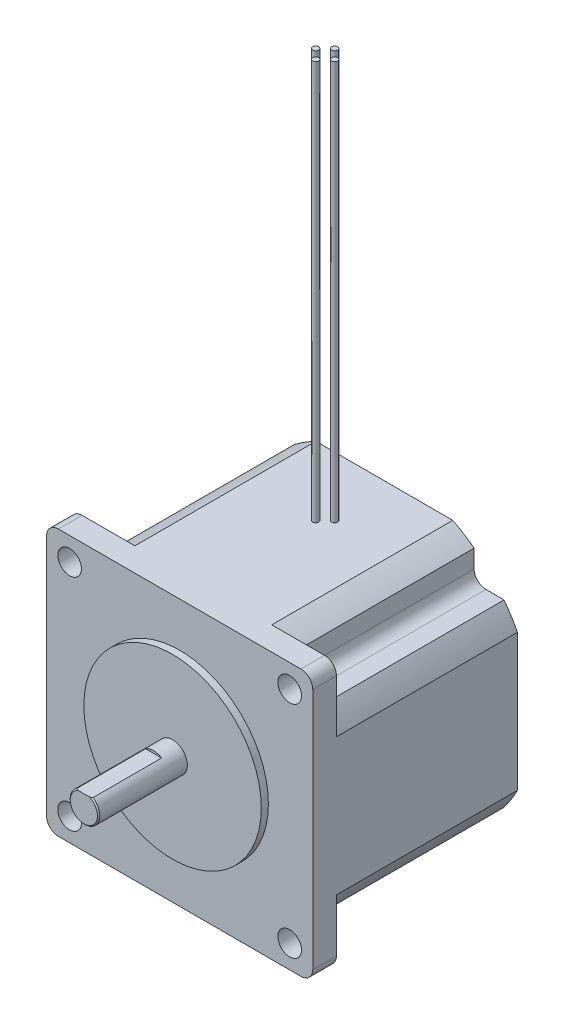
from build123d import *

# Parameters (mm, degrees)
ESQUISSE1_W             = 57.15
ESQUISSE1_H             = 57.15
BOSS_EXTRU_1_DEPTH      = 43.942
ENL_V_MAT_EXTRU_1_DEPTH = 38.862
ENL_V_MAT_EXTRU_2_DEPTH = 38.862
ENL_V_MAT_EXTRU_3_DEPTH = 38.862
ENL_V_MAT_EXTRU_4_DEPTH = 38.862
ENL_V_MAT_EXTRU_5_DEPTH = 38.862
ENL_V_MAT_EXTRU_6_DEPTH = 38.862
ENL_V_MAT_EXTRU_7_DEPTH = 38.862
ENL_V_MAT_EXTRU_8_DEPTH = 38.862
ESQUISSE10_R            = 19.05
BOSS_EXTRU_2_DEPTH      = 1.524
ESQUISSE11_R            = 3.175
BOSS_EXTRU_3_DEPTH      = 19.05
ENL_V_MAT_EXTRU_9_DEPTH = 14.986
ESQUISSE13_W            = 0.635
ESQUISSE13_H            = 85.725
ESQUISSE14_W            = 0.635
ESQUISSE14_H            = 85.725
ESQUISSE15_W            = 0.635
ESQUISSE15_H            = 85.725
ESQUISSE16_W            = 0.635
ESQUISSE16_H            = 85.725
PER_AGE1_D              = 5.08
PER_AGE1_DEPTH          = 25.654
CHANFREIN1_SIZE         = 0.254
CONG_1_R                = 2.54


with BuildPart() as part:
    # Esquisse1 → Boss.-Extru.1 (new body)
    with BuildSketch(Plane.XY.offset(43.942)):
        Rectangle(ESQUISSE1_W, ESQUISSE1_H)
    extrude(amount=-BOSS_EXTRU_1_DEPTH)

    # Esquisse2 → Enlèv. mat.-Extru.1 (cut)
    with BuildSketch(Plane(origin=(0, 0, 0), x_dir=(-1, 0, 0), z_dir=(0, 0, -1))):
        with BuildLine():
            Line((-28.575, -28.575), (-14.692533342, -28.575))
            ThreePointArc((-14.692533342, -28.575), (-22.720047986, -22.720047986), (-28.575, -14.692533342))
            Line((-28.575, -14.692533342), (-28.575, -28.575))
        make_face()
    extrude(amount=-ENL_V_MAT_EXTRU_1_DEPTH, mode=Mode.SUBTRACT)

    # Esquisse3 → Enlèv. mat.-Extru.2 (cut)
    with BuildSketch(Plane(origin=(0, 0, 0), x_dir=(-1, 0, 0), z_dir=(0, 0, -1))):
        with BuildLine():
            Line((-19.2786, -25.7048), (-19.2786, -19.2786))
            Line((-19.2786, -19.2786), (-25.7048, -19.2786))
            ThreePointArc((-25.7048, -19.2786), (-22.720047986, -22.720047986), (-19.2786, -25.7048))
        make_face()
    extrude(amount=-ENL_V_MAT_EXTRU_2_DEPTH, mode=Mode.SUBTRACT)

    # Esquisse4 → Enlèv. mat.-Extru.3 (cut)
    with BuildSketch(Plane(origin=(0, 0, 0), x_dir=(-1, 0, 0), z_dir=(0, 0, -1))):
        with BuildLine():
            Line((-28.575, 28.575), (-28.575, 14.692533342))
            ThreePointArc((-28.575, 14.692533342), (-22.720047986, 22.720047986), (-14.692533342, 28.575))
            Line((-14.692533342, 28.575), (-28.575, 28.575))
        make_face()
    extrude(amount=-ENL_V_MAT_EXTRU_3_DEPTH, mode=Mode.SUBTRACT)

    # Esquisse5 → Enlèv. mat.-Extru.4 (cut)
    with BuildSketch(Plane(origin=(0, 0, 0), x_dir=(-1, 0, 0), z_dir=(0, 0, -1))):
        with BuildLine():
            Line((-25.7048, 19.2786), (-19.2786, 19.2786))
            Line((-19.2786, 19.2786), (-19.2786, 25.7048))
            ThreePointArc((-19.2786, 25.7048), (-22.720047986, 22.720047986), (-25.7048, 19.2786))
        make_face()
    extrude(amount=-ENL_V_MAT_EXTRU_4_DEPTH, mode=Mode.SUBTRACT)

    # Esquisse6 → Enlèv. mat.-Extru.5 (cut)
    with BuildSketch(Plane(origin=(0, 0, 0), x_dir=(-1, 0, 0), z_dir=(0, 0, -1))):
        with BuildLine():
            Line((28.575, 28.575), (14.692533342, 28.575))
            ThreePointArc((14.692533342, 28.575), (22.720047986, 22.720047986), (28.575, 14.692533342))
            Line((28.575, 14.692533342), (28.575, 28.575))
        make_face()
    extrude(amount=-ENL_V_MAT_EXTRU_5_DEPTH, mode=Mode.SUBTRACT)

    # Esquisse7 → Enlèv. mat.-Extru.6 (cut)
    with BuildSketch(Plane(origin=(0, 0, 0), x_dir=(-1, 0, 0), z_dir=(0, 0, -1))):
        with BuildLine():
            Line((19.2786, 25.7048), (19.2786, 19.2786))
            Line((19.2786, 19.2786), (25.7048, 19.2786))
            ThreePointArc((25.7048, 19.2786), (22.720047986, 22.720047986), (19.2786, 25.7048))
        make_face()
    extrude(amount=-ENL_V_MAT_EXTRU_6_DEPTH, mode=Mode.SUBTRACT)

    # Esquisse8 → Enlèv. mat.-Extru.7 (cut)
    with BuildSketch(Plane(origin=(0, 0, 0), x_dir=(-1, 0, 0), z_dir=(0, 0, -1))):
        with BuildLine():
            Line((28.575, -28.575), (28.575, -14.692533342))
            ThreePointArc((28.575, -14.692533342), (22.720047986, -22.720047986), (14.692533342, -28.575))
            Line((14.692533342, -28.575), (28.575, -28.575))
        make_face()
    extrude(amount=-ENL_V_MAT_EXTRU_7_DEPTH, mode=Mode.SUBTRACT)

    # Esquisse9 → Enlèv. mat.-Extru.8 (cut)
    with BuildSketch(Plane(origin=(0, 0, 0), x_dir=(-1, 0, 0), z_dir=(0, 0, -1))):
        with BuildLine():
            Line((25.7048, -19.2786), (19.2786, -19.2786))
            Line((19.2786, -19.2786), (19.2786, -25.7048))
            ThreePointArc((19.2786, -25.7048), (22.720047986, -22.720047986), (25.7048, -19.2786))
        make_face()
    extrude(amount=-ENL_V_MAT_EXTRU_8_DEPTH, mode=Mode.SUBTRACT)

    # Esquisse10 → Boss.-Extru.2 (add)
    with BuildSketch(Plane.XY.offset(43.942)):
        Circle(ESQUISSE10_R)
    extrude(amount=BOSS_EXTRU_2_DEPTH)

    # Esquisse11 → Boss.-Extru.3 (add)
    with BuildSketch(Plane.XY.offset(45.466)):
        Circle(ESQUISSE11_R)
    extrude(amount=BOSS_EXTRU_3_DEPTH)

    # Esquisse12 → Enlèv. mat.-Extru.9 (cut)
    with BuildSketch(Plane.XY.offset(64.516)):
        with BuildLine():
            Line((-1.722711816, 2.667), (1.722711816, 2.667))
            ThreePointArc((1.722711816, 2.667), (0, 3.175), (-1.722711816, 2.667))
        make_face()
    extrude(amount=-ENL_V_MAT_EXTRU_9_DEPTH, mode=Mode.SUBTRACT)

    # Esquisse13 → Révolution1 (revolve)
    with BuildSketch(Plane(origin=(0, 0, 12.7), x_dir=(-1, 0, 0), z_dir=(0, 0, -1))):
        with Locations((1.7145, 71.4375)):
            Rectangle(ESQUISSE13_W, ESQUISSE13_H)
    revolve(axis=Axis((-2.032, 28.575, 12.7), (0, 1, 0)))

    # Esquisse14 → Révolution2 (revolve)
    with BuildSketch(Plane(origin=(0, 0, 12.7), x_dir=(-1, 0, 0), z_dir=(0, 0, -1))):
        with Locations((-2.3495, 71.4375)):
            Rectangle(ESQUISSE14_W, ESQUISSE14_H)
    revolve(axis=Axis((2.032, 28.575, 12.7), (0, 1, 0)))

    # Esquisse15 → Révolution3 (revolve)
    with BuildSketch(Plane(origin=(0, 0, 14.732), x_dir=(-1, 0, 0), z_dir=(0, 0, -1))):
        with Locations((-0.3175, 71.4375)):
            Rectangle(ESQUISSE15_W, ESQUISSE15_H)
    revolve(axis=Axis((0, 28.575, 14.732), (0, 1, 0)))

    # Esquisse16 → Révolution4 (revolve)
    with BuildSketch(Plane(origin=(0, 0, 10.668), x_dir=(-1, 0, 0), z_dir=(0, 0, -1))):
        with Locations((-0.3175, 71.4375)):
            Rectangle(ESQUISSE16_W, ESQUISSE16_H)
    revolve(axis=Axis((0, 28.575, 10.668), (0, 1, 0)))

    # Perçage1
    with Locations(Plane(origin=(0, 0, 38.862), x_dir=(-1, 0, 0), z_dir=(0, 0, -1))):
        with Locations((-23.622, -23.622), (-23.622, 23.622), (23.622, 23.622), (23.622, -23.622)):
            Hole(PER_AGE1_D / 2, depth=PER_AGE1_DEPTH)

    # Chanfrein1
    chanfrein1_edges = [part.edges().sort_by_distance(p)[0] for p in [
        (-1.51838977, -2.78838977, 64.516),
    ]]
    chamfer(chanfrein1_edges, length=CHANFREIN1_SIZE)

    # Congé1
    cong_1_edges = [part.edges().sort_by_distance(p)[0] for p in [
        (-19.2786, -19.2786, 19.431),
        (28.575, -28.575, 41.402),
        (19.2786, -19.2786, 19.431),
        (28.575, 28.575, 41.402),
        (19.2786, 19.2786, 19.431),
        (-28.575, 28.575, 41.402),
        (-19.2786, 19.2786, 19.431),
        (-28.575, -28.575, 41.402),
    ]]
    fillet(cong_1_edges, radius=CONG_1_R)


solid = part.part
